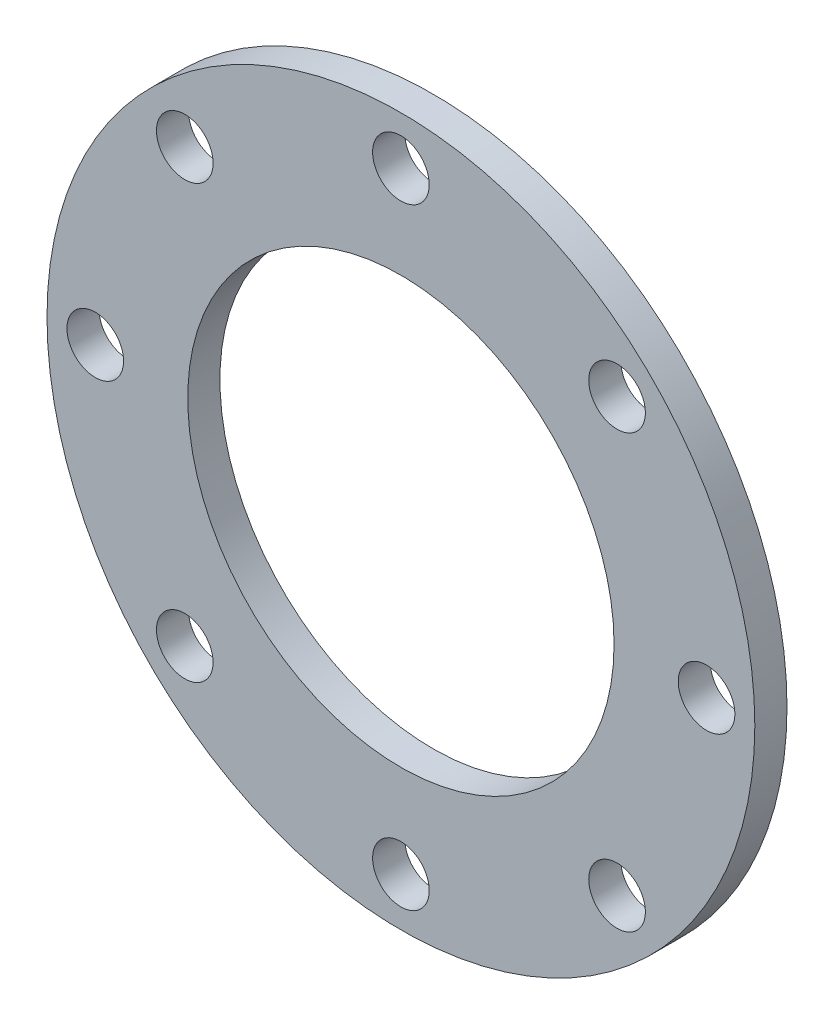
from build123d import *

# Parameters (mm, degrees)
SKETCH1_R           = 139.7
SKETCH1_R_2         = 84.1375
BOSS_EXTRUDE1_DEPTH = 12.7
SKETCH2_W           = 11.176
SKETCH2_H           = 12.7
CIRPATTERN1_COUNT   = 8


with BuildPart() as part:
    # Sketch1 → Boss-Extrude1 (new body)
    with BuildSketch(Plane.XY):
        Circle(SKETCH1_R)
        Circle(SKETCH1_R_2, mode=Mode.SUBTRACT)
    extrude(amount=BOSS_EXTRUDE1_DEPTH)

    # Sketch2 → 7/8 (0.88) Diameter Hole1 (revolve, cut)
    with BuildSketch(Plane(origin=(120.65, 0, 12.7), x_dir=(0, -1, 0), z_dir=(1, 0, 0))):
        with Locations((5.588, 6.35)):
            Rectangle(SKETCH2_W, SKETCH2_H)
    f_7_8_0_88_diameter_hole1 = revolve(axis=Axis((120.65, 0, 19.05), (0, 0, -1)), mode=Mode.SUBTRACT)

    # CirPattern1: 7/8 (0.88) Diameter Hole1 ×8 about axis
    cirpattern1_axis = Axis((0, 0, 0), (0, 0, 1))
    for i in range(1, CIRPATTERN1_COUNT):
        add(f_7_8_0_88_diameter_hole1.rotate(cirpattern1_axis, i * 360 / CIRPATTERN1_COUNT), mode=Mode.SUBTRACT)


solid = part.part
